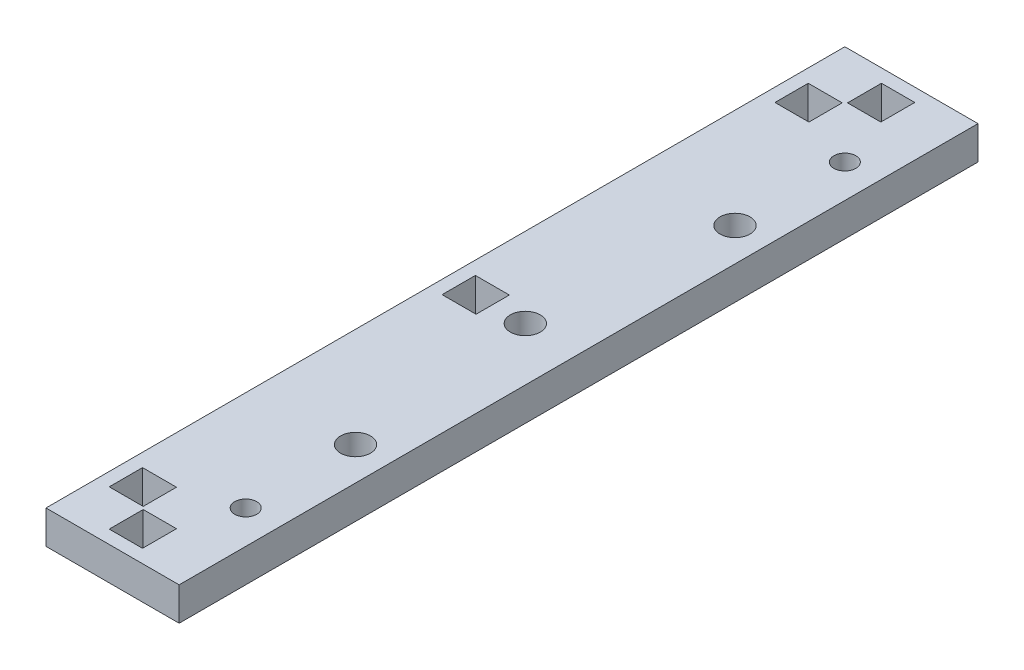
from build123d import *

# Parameters (mm, degrees)
SKETCH1_W                  = 20
SKETCH1_H                  = 120
BOSS_EXTRUDE1_DEPTH        = 5
F_3_3_3_3_DIAMETER_HOLE1_D = 3.3
SKETCH5_W                  = 5.1
SKETCH5_H                  = 5
SKETCH5_W_2                = 5
SKETCH5_H_2                = 5.1
CUT_EXTRUDE1_DEPTH         = 6
F_4_5_4_5_DIAMETER_HOLE2_D = 4.5


with BuildPart() as part:
    # Sketch1 → Boss-Extrude1 (new body)
    with BuildSketch(Plane(origin=(0, 0, 0), x_dir=(1, 0, 0), z_dir=(0, 1, 0))):
        Rectangle(SKETCH1_W, SKETCH1_H)
    extrude(amount=BOSS_EXTRUDE1_DEPTH)

    # Ø3.3 (3.3) Diameter Hole1 (through all)
    with Locations(Plane(origin=(0, 5, 0), x_dir=(1, 0, 0), z_dir=(0, 1, 0))):
        with Locations((5, 45), (5, -45)):
            Hole(F_3_3_3_3_DIAMETER_HOLE1_D / 2)

    # Sketch5 → Cut-Extrude1 (cut, through all)
    with BuildSketch(Plane(origin=(0, 5, 0), x_dir=(1, 0, 0), z_dir=(0, 1, 0))):
        with Locations((-5.45, 50)):
            Rectangle(SKETCH5_W, SKETCH5_H)
        with Locations((-5.45, -50)):
            Rectangle(SKETCH5_W, SKETCH5_H)
        with Locations((0, -55.45)):
            Rectangle(SKETCH5_W_2, SKETCH5_H_2)
        with Locations((0, 55.45)):
            Rectangle(SKETCH5_W_2, SKETCH5_H_2)
        with Locations((-5.45, 0)):
            Rectangle(SKETCH5_W, SKETCH5_H)
    extrude(amount=-CUT_EXTRUDE1_DEPTH, mode=Mode.SUBTRACT)

    # Ø4.5 (4.5) Diameter Hole2 (through all)
    with Locations(Plane(origin=(0, 5, 0), x_dir=(1, 0, 0), z_dir=(0, 1, 0))):
        with Locations((5, 28.5), (2, 0), (5, -28.5)):
            Hole(F_4_5_4_5_DIAMETER_HOLE2_D / 2)


solid = part.part
